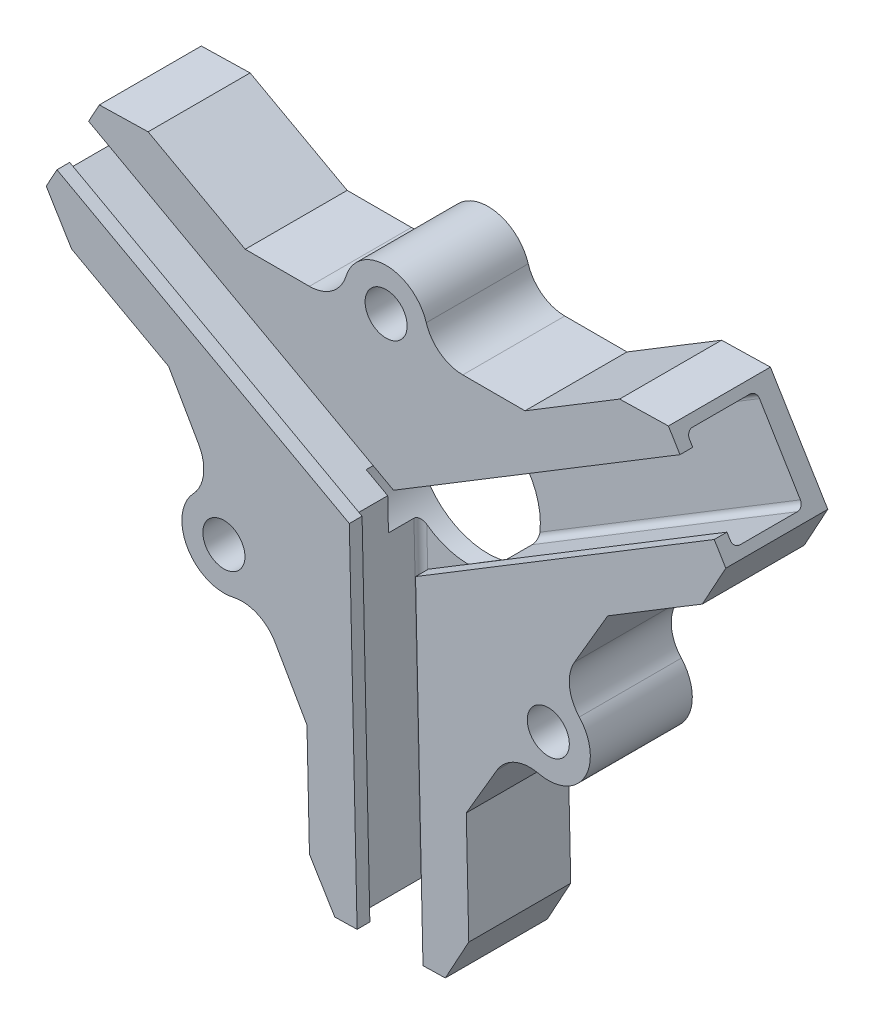
from build123d import *

# Parameters (mm, degrees)
SKETCH1_R                        = 1.65
SKETCH1_R_2                      = 2.565
BOSS_EXTRUDE2_DEPTH              = 8
CUT_EXTRUDE1_REACH               = 80.832
CUT_EXTRUDE1_OFFSET_FROM_SURFACE = 13
CUT_EXTRUDE2_REACH               = 61.944
CUT_EXTRUDE2_OFFSET_FROM_SURFACE = 13
CUT_EXTRUDE3_REACH               = 80.174
CUT_EXTRUDE3_OFFSET_FROM_SURFACE = 13
FILLET1_R                        = 3
FILLET2_R                        = 0.5
SKETCH5_R                        = 5.6
CUT_EXTRUDE4_DEPTH               = 4


with BuildPart() as part:
    # Sketch1 → Boss-Extrude2 (new body)
    with BuildSketch(Plane.XY):
        with BuildLine():
            Line((-15.818539514, 20.899253914), (-23.777051469, 20.899253914))
            Line((-23.777051469, 20.899253914), (-31.392628778, 25.071578724))
            Line((-31.392628778, 25.071578724), (-35.221090626, 24.985827798))
            Line((-35.221090626, 24.985827798), (-39.387147416, 17.381691254))
            Line((-39.387147416, 17.381691254), (-37.398654012, 14.109021499))
            Line((-37.398654012, 14.109021499), (-29.783076702, 9.93669669))
            Line((-29.783076702, 9.93669669), (-25.956088039, 3.258254515))
            ThreePointArc((-25.956088039, 3.258254515), (-28.308678707, -1.639592518), (-22.893505274, -2.086230066))
            Line((-22.893505274, -2.086230066), (-18.931323152, -9.000597084))
            Line((-18.931323152, -9.000597084), (-18.736873775, -17.682042904))
            Line((-18.736873775, -17.682042904), (-16.748380371, -20.954712658))
            Line((-16.748380371, -20.954712658), (-8.079976555, -20.7605554))
            Line((-8.079976555, -20.7605554), (-6.240008112, -17.402134719))
            Line((-6.240008112, -17.402134719), (-6.434457489, -8.7206889))
            Line((-6.434457489, -8.7206889), (-2.549592829, -2.09153546))
            ThreePointArc((-2.549592829, -2.09153546), (2.845157596, -1.667339925), (0.578670581, 3.246549635))
            Line((0.578670581, 3.246549635), (4.66331299, 10.216604874))
            Line((4.66331299, 10.216604874), (12.084440923, 14.725725884))
            Line((12.084440923, 14.725725884), (13.924409366, 18.084146564))
            Line((13.924409366, 18.084146564), (9.42206234, 25.49412585))
            Line((9.42206234, 25.49412585), (5.593600493, 25.408374924))
            Line((5.593600493, 25.408374924), (-1.82752744, 20.899253914))
            Line((-1.82752744, 20.899253914), (-9.628901603, 20.899253914))
            ThreePointArc((-9.628901603, 20.899253914), (-12.723720558, 25.335848494), (-15.818539514, 20.899253914))
        make_face()
        Circle(SKETCH1_R, mode=Mode.SUBTRACT)
        with Locations((-25.447441117, 0)):
            Circle(SKETCH1_R, mode=Mode.SUBTRACT)
        with Locations((-12.723720558, 22.038130468)):
            Circle(SKETCH1_R, mode=Mode.SUBTRACT)
        with Locations((-12.723720558, 7.346043489)):
            Circle(SKETCH1_R_2, mode=Mode.SUBTRACT)
    extrude(amount=BOSS_EXTRUDE2_DEPTH)

    # Cut-Extrude1: up to this face of the body (flat: up to its plane, moved by the offset)
    cut_extrude1_end = Plane(part.part.faces().sort_by_distance((-27.869582371, 6.597475602, 4))[0]).offset(-CUT_EXTRUDE1_OFFSET_FROM_SURFACE)
    # Sketch2 → Cut-Extrude1 (cut, up to the picked face)
    with BuildSketch(Plane(origin=(18.195090402, 11.055444017, 0), x_dir=(0, 0, -1), z_dir=(0.854611923, 0.519267234, 0)), mode=Mode.PRIVATE) as cut_extrude1_sk1:
        Polygon((-1.5, 8.974437732), (-1.5, 16.145015669), (-7, 16.145015669), (-7, 15.145015669), (-8, 15.145015669), (-8, 9.974437732), (-7, 9.974437732), (-7, 8.974437732), align=None)
    cut_extrude1_tool1 = split(extrude(cut_extrude1_sk1.sketch, amount=-CUT_EXTRUDE1_REACH, mode=Mode.PRIVATE), bisect_by=cut_extrude1_end, keep=Keep.BOTH, mode=Mode.PRIVATE)
    add(cut_extrude1_tool1.solids().sort_by_distance((11.673236, 21.789136, 4.626706))[0], mode=Mode.SUBTRACT)

    # Cut-Extrude2: up to this face of the body (flat: up to its plane, moved by the offset)
    cut_extrude2_end = Plane(part.part.faces().sort_by_distance((-5.728214521, 20.899253914, 4))[0]).offset(-CUT_EXTRUDE2_OFFSET_FROM_SURFACE)
    # Sketch3 → Cut-Extrude2 (cut, up to the picked face)
    with BuildSketch(Plane(origin=(0.460715831, -20.569258657, 0), x_dir=(0.999749253, 0.022392655, 0), z_dir=(0.022392655, -0.999749253, 0)), mode=Mode.PRIVATE) as cut_extrude2_sk1:
        Polygon((-16.463412412, 1.5), (-9.292834476, 1.5), (-9.292834476, 7), (-10.292834476, 7), (-10.292834476, 8), (-15.463412412, 8), (-15.463412412, 7), (-16.463412412, 7), align=None)
    cut_extrude2_tool1 = split(extrude(cut_extrude2_sk1.sketch, amount=-CUT_EXTRUDE2_REACH, mode=Mode.PRIVATE), bisect_by=cut_extrude2_end, keep=Keep.BOTH, mode=Mode.PRIVATE)
    add(cut_extrude2_tool1.solids().sort_by_distance((-12.414178, -20.857634, 4.626706))[0], mode=Mode.SUBTRACT)

    # Cut-Extrude3: up to this face of the body (flat: up to its plane, moved by the offset)
    cut_extrude3_end = Plane(part.part.faces().sort_by_distance((2.620991785, 6.731577255, 4))[0]).offset(-CUT_EXTRUDE3_OFFSET_FROM_SURFACE)
    # Sketch4 → Cut-Extrude3 (cut, up to the picked face)
    with BuildSketch(Plane(origin=(-37.618496326, 20.609939227, 0), x_dir=(0, 0, 1), z_dir=(-0.877004578, 0.480482019, 0)), mode=Mode.PRIVATE) as cut_extrude3_sk1:
        Polygon((1.5, 4.23958464), (1.5, -2.930993297), (7, -2.930993297), (7, -1.930993297), (8, -1.930993297), (8, 3.23958464), (7, 3.23958464), (7, 4.23958464), align=None)
    cut_extrude3_tool1 = split(extrude(cut_extrude3_sk1.sketch, amount=-CUT_EXTRUDE3_REACH, mode=Mode.PRIVATE), bisect_by=cut_extrude3_end, keep=Keep.BOTH, mode=Mode.PRIVATE)
    add(cut_extrude3_tool1.solids().sort_by_distance((-37.304119, 21.18376, 4.626706))[0], mode=Mode.SUBTRACT)

    # Fillet1
    fillet1_edges = [part.edges().sort_by_distance(p)[0] for p in [
        (-2.549592829, -2.09153546, 4),
        (-22.893505274, -2.086230066, 4),
        (-25.956088039, 3.258254515, 4),
        (-15.818539514, 20.899253914, 4),
        (-9.628901603, 20.899253914, 4),
        (0.578670581, 3.246549635, 4),
    ]]
    fillet(fillet1_edges, radius=FILLET1_R)

    # Fillet2
    fillet2_edges = [part.edges().sort_by_distance(p)[0] for p in [
        (2.066272904, 11.756664371, 1.5),
        (2.066272904, 11.756664371, 7),
        (-9.116100814, -7.994563327, 7),
        (-9.116100814, -7.994563327, 1.5),
        (-16.297456112, -7.593688192, 7),
        (-16.297456112, -7.593688192, 1.5),
        (-1.177236693, 18.176338061, 1.5),
        (-1.177236693, 18.176338061, 7),
        (-23.873719146, 17.913791789, 7),
        (-23.873719146, 17.913791789, 1.5),
        (-27.811564847, 11.894993235, 7),
        (-27.811564847, 11.894993235, 1.5),
    ]]
    fillet(fillet2_edges, radius=FILLET2_R)

    # Sketch5 → Cut-Extrude4 (cut)
    with BuildSketch(Plane(origin=(0, 0, 0), x_dir=(-1, 0, 0), z_dir=(0, 0, -1))):
        with Locations((12.723720558, 7.346043489)):
            Circle(SKETCH5_R)
    extrude(amount=-CUT_EXTRUDE4_DEPTH, mode=Mode.SUBTRACT)


solid = part.part
